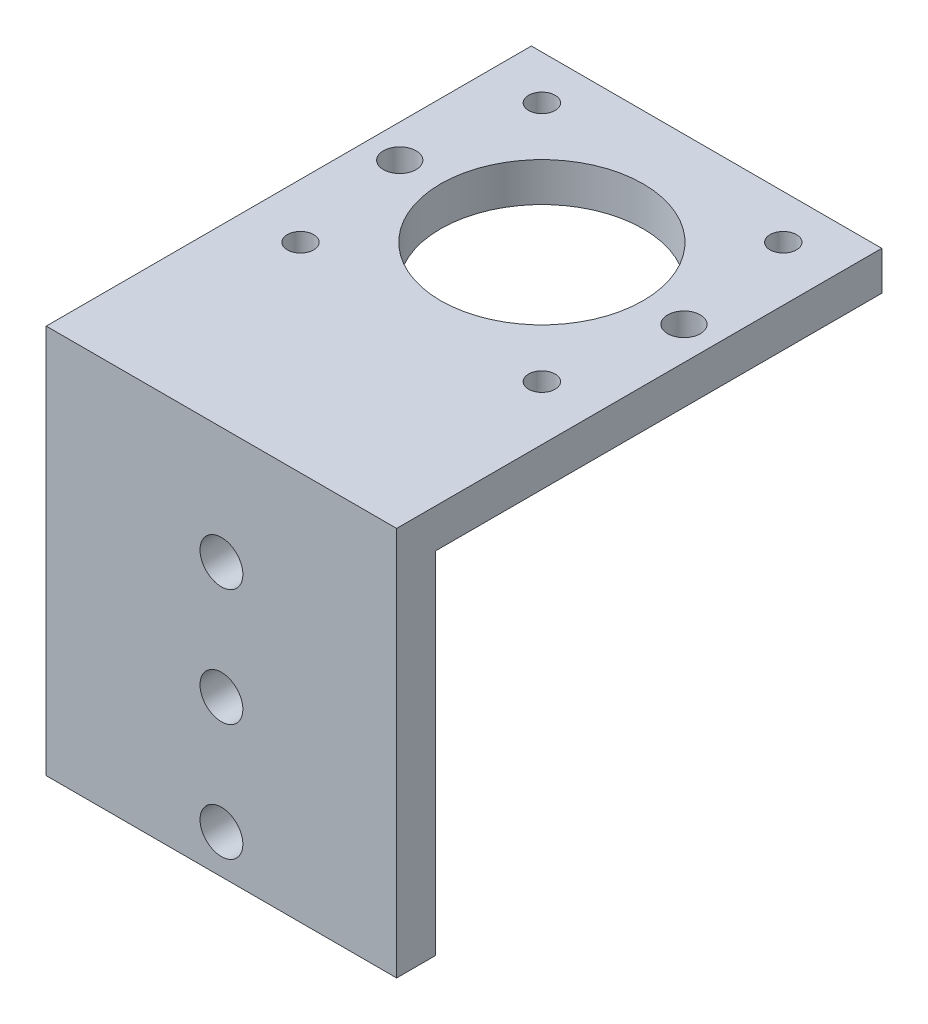
from build123d import *

# Parameters (mm, degrees)
SKETCH2_W             = 45
SKETCH2_H             = 42.3
BOSS_EXTRUDE1_DEPTH   = 5
BOSS_EXTRUDE2_DEPTH   = 45
M5_CLEARANCE_HOLE1_D  = 5.5
SKETCH6_R             = 13
CUT_EXTRUDE1_DEPTH    = 5
M3_CLEARANCE_HOLE1_D  = 3.4
M5X0_8_TAPPED_HOLE1_D = 4.2


with BuildPart() as part:
    # Sketch2 → Boss-Extrude1 (new body)
    with BuildSketch(Plane(origin=(0, 0, 0), x_dir=(1, 0, 0), z_dir=(0, 1, 0))):
        Rectangle(SKETCH2_W, SKETCH2_H)
    extrude(amount=BOSS_EXTRUDE1_DEPTH)

    # Sketch3 → Boss-Extrude2 (add, through all)
    with BuildSketch(Plane(origin=(22.5, 0, 0), x_dir=(0, 0, -1), z_dir=(1, 0, 0))):
        Polygon((-21.15, 0), (-36.15, 0), (-36.15, -45), (-41.15, -45), (-41.15, 5), (-21.15, 5), align=None)
    extrude(amount=-BOSS_EXTRUDE2_DEPTH)

    # M5 Clearance Hole1 (through all)
    with Locations(Plane(origin=(0, 0, 36.15), x_dir=(-1, 0, 0), z_dir=(0, 0, -1))):
        with Locations((0, -10), (0, -25), (0, -40)):
            Hole(M5_CLEARANCE_HOLE1_D / 2)

    # Sketch6 → Cut-Extrude1 (cut)
    with BuildSketch(Plane(origin=(0, 5, 0), x_dir=(1, 0, 0), z_dir=(0, 1, 0))):
        Circle(SKETCH6_R)
    extrude(amount=-CUT_EXTRUDE1_DEPTH, mode=Mode.SUBTRACT)

    # M3 Clearance Hole1 (through all)
    with Locations(Plane(origin=(0, 5, 0), x_dir=(1, 0, 0), z_dir=(0, 1, 0))):
        with Locations((-15.5, 15.5), (-15.5, -15.5), (15.5, -15.5), (15.5, 15.5)):
            Hole(M3_CLEARANCE_HOLE1_D / 2)

    # M5x0.8 Tapped Hole1 (through all)
    with Locations(Plane(origin=(0, 5, 0), x_dir=(1, 0, 0), z_dir=(0, 1, 0))):
        with Locations((-18.25, 0), (18.25, 0)):
            Hole(M5X0_8_TAPPED_HOLE1_D / 2)


solid = part.part
